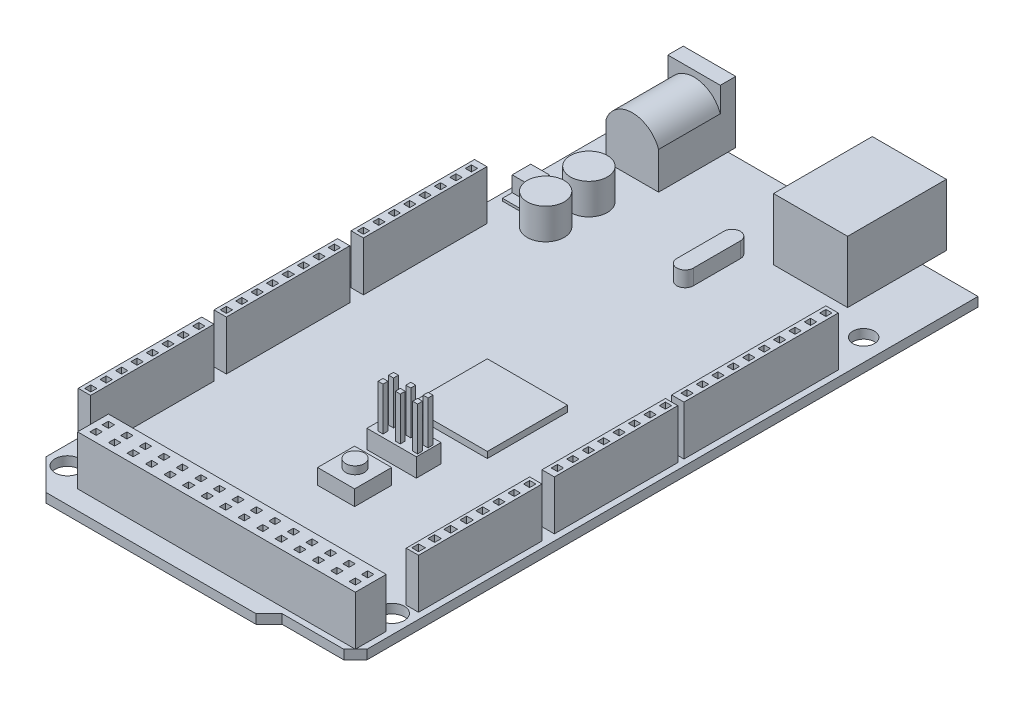
from build123d import *

# Parameters (mm, degrees)
BOSS_EXTRUDE3_DEPTH  = 1.5
SKETCH4_W            = 45
SKETCH4_H            = 5
BOSS_EXTRUDE5_DEPTH  = 8
SKETCH7_W            = 1
SKETCH7_H            = 1
CUT_EXTRUDE1_DEPTH   = 8
SKETCH8_W            = 6
SKETCH8_H            = 6
BOSS_EXTRUDE7_DEPTH  = 2.5
SKETCH10_R           = 1.5
BOSS_EXTRUDE8_DEPTH  = 1.25
SKETCH11_W           = 8
SKETCH11_H           = 4
BOSS_EXTRUDE9_DEPTH  = 3
SKETCH12_W           = 0.8
SKETCH12_H           = 0.8
BOSS_EXTRUDE10_DEPTH = 7
SKETCH13_W           = 13
SKETCH13_H           = 13
BOSS_EXTRUDE11_DEPTH = 1
SKETCH14_W           = 12
SKETCH14_H           = 16
BOSS_EXTRUDE12_DEPTH = 10
CUT_EXTRUDE2_DEPTH   = 13
SKETCH16_W           = 5.556040393
SKETCH16_H           = 3.382310536
BOSS_EXTRUDE13_DEPTH = 13
SKETCH17_W           = 8.5
SKETCH17_H           = 10
BOSS_EXTRUDE14_DEPTH = 1.25
BOSS_EXTRUDE15_DEPTH = 10
SKETCH19_R           = 3
CUT_EXTRUDE6_DEPTH   = 10
SKETCH20_R           = 0.5
BOSS_EXTRUDE16_DEPTH = 8
DOME1_FACE_RADIUS    = 0.5
DOME1_HEIGHT         = 1
SKETCH21_R           = 3
BOSS_EXTRUDE17_DEPTH = 5
SKETCH23_W           = 3.025680813
SKETCH23_H           = 6.185836328
BOSS_EXTRUDE18_DEPTH = 0.4
SKETCH24_W           = 3.025680813
SKETCH24_H           = 3.010787739
BOSS_EXTRUDE19_DEPTH = 2.5
BOSS_EXTRUDE20_DEPTH = 2.5
SKETCH26_R           = 2
CUT_EXTRUDE7_DEPTH   = 1.5
SKETCH27_R           = 2
CUT_EXTRUDE8_DEPTH   = 1.5
SKETCH28_R           = 2
CUT_EXTRUDE9_DEPTH   = 1.5
SKETCH29_W           = 2
SKETCH29_H           = 20
BOSS_EXTRUDE21_DEPTH = 8
SKETCH30_W           = 1
SKETCH30_H           = 1
SKETCH30_W_2         = 1.1
SKETCH30_H_2         = 1.1
CUT_EXTRUDE10_DEPTH  = 8
SKETCH32_W           = 2
SKETCH32_H           = 20
BOSS_EXTRUDE22_DEPTH = 8
SKETCH34_W           = 1
SKETCH34_H           = 1
CUT_EXTRUDE11_DEPTH  = 8
LPATTERN1_COUNT      = 8
LPATTERN1_PITCH      = 2.5
SKETCH37_W           = 2
SKETCH37_H           = 25
BOSS_EXTRUDE24_DEPTH = 8
SKETCH41_W           = 1
SKETCH41_H           = 1
CUT_EXTRUDE13_DEPTH  = 8
LPATTERN3_COUNT      = 10
LPATTERN3_PITCH      = 2.5
SKETCH45_R           = 1.75
CUT_EXTRUDE14_DEPTH  = 1.5
SKETCH46_W           = 2
SKETCH46_H           = 20
BOSS_EXTRUDE25_DEPTH = 8
SKETCH47_W           = 1
SKETCH47_H           = 1
CUT_EXTRUDE15_DEPTH  = 8
LPATTERN4_COUNT      = 8
LPATTERN4_PITCH      = 2.5
SKETCH49_W           = 2
SKETCH49_H           = 20
BOSS_EXTRUDE26_DEPTH = 8
SKETCH50_W           = 1
SKETCH50_H           = 1
CUT_EXTRUDE16_DEPTH  = 8
LPATTERN5_COUNT      = 8
LPATTERN5_PITCH      = 2.5
SKETCH52_W           = 2
SKETCH52_H           = 20
BOSS_EXTRUDE27_DEPTH = 8
SKETCH53_W           = 1
SKETCH53_H           = 1
CUT_EXTRUDE17_DEPTH  = 8
LPATTERN6_COUNT      = 8
LPATTERN6_PITCH      = 2.5


with BuildPart() as part:
    # Sketch1 → Boss-Extrude3 (new body)
    with BuildSketch(Plane(origin=(0, 0, 0), x_dir=(1, 0, 0), z_dir=(0, 1, 0))):
        Polygon((0, 0), (34, 0), (36.121320344, 2.121320344), (46.121320344, 2.121320344), (48, 4), (48, 103), (-5, 103), (-5, 5), align=None)
    extrude(amount=BOSS_EXTRUDE3_DEPTH)

    # Sketch4 → Boss-Extrude5 (add)
    with BuildSketch(Plane(origin=(0, 1.5, 0), x_dir=(1, 0, 0), z_dir=(0, 1, 0))):
        with Locations((24.560660172, 5.560660172)):
            Rectangle(SKETCH4_W, SKETCH4_H)
    extrude(amount=BOSS_EXTRUDE5_DEPTH)

    # Sketch7 → Cut-Extrude1 (cut)
    with BuildSketch(Plane(origin=(0, 9.5, 0), x_dir=(1, 0, 0), z_dir=(0, 1, 0))):
        with Locations((45.560660172, 6.560660172)):
            Rectangle(SKETCH7_W, SKETCH7_H)
        with Locations((45.560660172, 4.560660172)):
            Rectangle(SKETCH7_W, SKETCH7_H)
        with Locations((42.560660172, 4.560660172)):
            Rectangle(SKETCH7_W, SKETCH7_H)
        with Locations((42.560660172, 6.540676592)):
            Rectangle(SKETCH7_W, SKETCH7_H)
        with Locations((39.560660172, 6.540676592)):
            Rectangle(SKETCH7_W, SKETCH7_H)
        with Locations((39.560660172, 4.560660172)):
            Rectangle(SKETCH7_W, SKETCH7_H)
        with Locations((36.560660172, 4.560660172)):
            Rectangle(SKETCH7_W, SKETCH7_H)
        with Locations((36.560660172, 6.540676592)):
            Rectangle(SKETCH7_W, SKETCH7_H)
        with Locations((33.560660172, 6.540676592)):
            Rectangle(SKETCH7_W, SKETCH7_H)
        with Locations((33.560660172, 4.560660172)):
            Rectangle(SKETCH7_W, SKETCH7_H)
        with Locations((30.560660172, 4.560660172)):
            Rectangle(SKETCH7_W, SKETCH7_H)
        with Locations((30.560660172, 6.540676592)):
            Rectangle(SKETCH7_W, SKETCH7_H)
        with Locations((27.560660172, 6.540676592)):
            Rectangle(SKETCH7_W, SKETCH7_H)
        with Locations((27.560660172, 4.560660172)):
            Rectangle(SKETCH7_W, SKETCH7_H)
        with Locations((24.560660172, 6.540676592)):
            Rectangle(SKETCH7_W, SKETCH7_H)
        with Locations((21.560660172, 6.540676592)):
            Rectangle(SKETCH7_W, SKETCH7_H)
        with Locations((24.560660172, 4.560660172)):
            Rectangle(SKETCH7_W, SKETCH7_H)
        with Locations((18.560660172, 6.540676592)):
            Rectangle(SKETCH7_W, SKETCH7_H)
        with Locations((15.560660172, 6.540676592)):
            Rectangle(SKETCH7_W, SKETCH7_H)
        with Locations((21.560660172, 4.560660172)):
            Rectangle(SKETCH7_W, SKETCH7_H)
        with Locations((18.560660172, 4.560660172)):
            Rectangle(SKETCH7_W, SKETCH7_H)
        with Locations((12.560660172, 6.540676592)):
            Rectangle(SKETCH7_W, SKETCH7_H)
        with Locations((9.560660172, 6.540676592)):
            Rectangle(SKETCH7_W, SKETCH7_H)
        with Locations((15.560660172, 4.560660172)):
            Rectangle(SKETCH7_W, SKETCH7_H)
        with Locations((6.560660172, 6.540676592)):
            Rectangle(SKETCH7_W, SKETCH7_H)
        with Locations((3.560660172, 6.540676592)):
            Rectangle(SKETCH7_W, SKETCH7_H)
        with Locations((12.560660172, 4.560660172)):
            Rectangle(SKETCH7_W, SKETCH7_H)
        with Locations((9.560660172, 4.560660172)):
            Rectangle(SKETCH7_W, SKETCH7_H)
        with Locations((6.560660172, 4.560660172)):
            Rectangle(SKETCH7_W, SKETCH7_H)
        with Locations((3.560660172, 4.560660172)):
            Rectangle(SKETCH7_W, SKETCH7_H)
    extrude(amount=-CUT_EXTRUDE1_DEPTH, mode=Mode.SUBTRACT)

    # Sketch8 → Boss-Extrude7 (add)
    with BuildSketch(Plane(origin=(0, 1.5, 0), x_dir=(1, 0, 0), z_dir=(0, 1, 0))):
        with Locations((24, 26)):
            Rectangle(SKETCH8_W, SKETCH8_H)
    extrude(amount=BOSS_EXTRUDE7_DEPTH)

    # Sketch10 → Boss-Extrude8 (add)
    with BuildSketch(Plane(origin=(0, 4, 0), x_dir=(1, 0, 0), z_dir=(0, 1, 0))):
        with Locations((24, 26.073311565)):
            Circle(SKETCH10_R)
    extrude(amount=BOSS_EXTRUDE8_DEPTH)

    # Sketch11 → Boss-Extrude9 (add)
    with BuildSketch(Plane(origin=(0, 1.5, 0), x_dir=(1, 0, 0), z_dir=(0, 1, 0))):
        with Locations((24, 34)):
            Rectangle(SKETCH11_W, SKETCH11_H)
    extrude(amount=BOSS_EXTRUDE9_DEPTH)

    # Sketch12 → Boss-Extrude10 (add)
    with BuildSketch(Plane(origin=(0, 4.5, 0), x_dir=(1, 0, 0), z_dir=(0, 1, 0))):
        with Locations((27.3, 34.6)):
            Rectangle(SKETCH12_W, SKETCH12_H)
        with Locations((24.5, 34.6)):
            Rectangle(SKETCH12_W, SKETCH12_H)
        with Locations((21.7, 34.6)):
            Rectangle(SKETCH12_W, SKETCH12_H)
        with Locations((21.7, 32.9)):
            Rectangle(SKETCH12_W, SKETCH12_H)
        with Locations((24.5, 32.9)):
            Rectangle(SKETCH12_W, SKETCH12_H)
        with Locations((27.3, 32.9)):
            Rectangle(SKETCH12_W, SKETCH12_H)
    extrude(amount=BOSS_EXTRUDE10_DEPTH)

    # Sketch13 → Boss-Extrude11 (add)
    with BuildSketch(Plane(origin=(0, 1.5, 0), x_dir=(1, 0, 0), z_dir=(0, 1, 0))):
        with Locations((24.5, 47)):
            Rectangle(SKETCH13_W, SKETCH13_H)
    extrude(amount=BOSS_EXTRUDE11_DEPTH)

    # Sketch14 → Boss-Extrude12 (add)
    with BuildSketch(Plane(origin=(0, 1.5, 0), x_dir=(1, 0, 0), z_dir=(0, 1, 0))):
        with Locations((33, 98.872790312)):
            Rectangle(SKETCH14_W, SKETCH14_H)
    extrude(amount=BOSS_EXTRUDE12_DEPTH)

    # Sketch15 → Cut-Extrude2 (cut)
    with BuildSketch(Plane(origin=(0, 0, -106.872790312), x_dir=(-1, 0, 0), z_dir=(0, 0, -1))):
        Polygon((-37.504201852, 2.874498731), (-37.504201852, 7.776667234), (-35.780869086, 9.5), (-30.271494225, 9.5), (-28.548161459, 7.776667234), (-28.548161459, 2.874498731), align=None)
    extrude(amount=-CUT_EXTRUDE2_DEPTH, mode=Mode.SUBTRACT)

    # Sketch16 → Boss-Extrude13 (add)
    with BuildSketch(Plane(origin=(0, 0, -93.872790312), x_dir=(-1, 0, 0), z_dir=(0, 0, -1))):
        with Locations((-33.026181656, 6.088795598)):
            Rectangle(SKETCH16_W, SKETCH16_H)
    extrude(amount=BOSS_EXTRUDE13_DEPTH)

    # Sketch17 → Boss-Extrude14 (add, symmetric)
    with BuildSketch(Plane(origin=(0, 0, -103), x_dir=(-1, 0, 0), z_dir=(0, 0, -1))):
        with Locations((-3.25, 6.5)):
            Rectangle(SKETCH17_W, SKETCH17_H)
    extrude(amount=BOSS_EXTRUDE14_DEPTH, both=True)

    # Sketch18 → Boss-Extrude15 (add)
    with BuildSketch(Plane.XY.offset(-101.75)):
        with BuildLine():
            Line((-1, 7.5), (-1, 1.5))
            Line((-1, 1.5), (7.5, 1.5))
            Line((7.5, 1.5), (7.5, 7.5))
            ThreePointArc((7.5, 7.5), (3.25, 10.520980054), (-1, 7.5))
        make_face()
    extrude(amount=BOSS_EXTRUDE15_DEPTH)

    # Sketch19 → Cut-Extrude6 (cut)
    with BuildSketch(Plane(origin=(0, 0, -104.25), x_dir=(-1, 0, 0), z_dir=(0, 0, -1))):
        with Locations((-3, 6.5)):
            Circle(SKETCH19_R)
    extrude(amount=-CUT_EXTRUDE6_DEPTH, mode=Mode.SUBTRACT)

    # Sketch20 → Boss-Extrude16 (add)
    with BuildSketch(Plane(origin=(0, 0, -94.25), x_dir=(-1, 0, 0), z_dir=(0, 0, -1))):
        with Locations((-3, 6.5)):
            Circle(SKETCH20_R)
    extrude(amount=BOSS_EXTRUDE16_DEPTH)

    # Dome1: a dome of height H over a round flat face of radius A is a cap of a sphere of radius (A * A + H * H) / (2 * H)
    dome1_r = (DOME1_FACE_RADIUS * DOME1_FACE_RADIUS + DOME1_HEIGHT * DOME1_HEIGHT) / (2 * DOME1_HEIGHT)
    dome1_base = Plane((3, 6.5, -102.25), z_dir=(0, 0, -1))
    with Locations(dome1_base.offset(DOME1_HEIGHT - dome1_r)):
        dome1_ball = Sphere(dome1_r, mode=Mode.PRIVATE)
    add(split(dome1_ball, bisect_by=dome1_base, keep=Keep.TOP, mode=Mode.PRIVATE))

    # Sketch21 → Boss-Extrude17 (add)
    with BuildSketch(Plane(origin=(0, 1.5, 0), x_dir=(1, 0, 0), z_dir=(0, 1, 0))):
        with Locations((3.204807184, 84.75)):
            Circle(SKETCH21_R)
        with Locations((3.204807184, 77.75)):
            Circle(SKETCH21_R)
    extrude(amount=BOSS_EXTRUDE17_DEPTH)

    # Sketch23 → Boss-Extrude18 (add)
    with BuildSketch(Plane(origin=(0, 1.5, 0), x_dir=(1, 0, 0), z_dir=(0, 1, 0))):
        with Locations((-2.384923748, 80.942657666)):
            Rectangle(SKETCH23_W, SKETCH23_H)
    extrude(amount=BOSS_EXTRUDE18_DEPTH)

    # Sketch24 → Boss-Extrude19 (add)
    with BuildSketch(Plane(origin=(0, 1.9, 0), x_dir=(1, 0, 0), z_dir=(0, 1, 0))):
        with Locations((-2.384923748, 80.930065048)):
            Rectangle(SKETCH24_W, SKETCH24_H)
    extrude(amount=BOSS_EXTRUDE19_DEPTH)

    # Sketch25 → Boss-Extrude20 (add)
    with BuildSketch(Plane(origin=(0, 1.5, 0), x_dir=(1, 0, 0), z_dir=(0, 1, 0))):
        with BuildLine():
            Line((20.771758804, 89.050138078), (20.771758804, 81.430202035))
            ThreePointArc((20.771758804, 81.430202035), (22.112303108, 80.089657731), (23.452847412, 81.430202035))
            Line((23.452847412, 81.430202035), (23.452847412, 89.050138078))
            ThreePointArc((23.452847412, 89.050138078), (22.112303108, 90.390682382), (20.771758804, 89.050138078))
        make_face()
    extrude(amount=BOSS_EXTRUDE20_DEPTH)

    # Sketch26 → Cut-Extrude7 (cut)
    with BuildSketch(Plane(origin=(0, 1.5, 0), x_dir=(1, 0, 0), z_dir=(0, 1, 0))):
        with Locations((-2, 89)):
            Circle(SKETCH26_R)
    extrude(amount=-CUT_EXTRUDE7_DEPTH, mode=Mode.SUBTRACT)

    # Sketch27 → Cut-Extrude8 (cut)
    with BuildSketch(Plane(origin=(0, 1.5, 0), x_dir=(1, 0, 0), z_dir=(0, 1, 0))):
        with Locations((-2, 5.472916024)):
            Circle(SKETCH27_R)
    extrude(amount=-CUT_EXTRUDE8_DEPTH, mode=Mode.SUBTRACT)

    # Sketch28 → Cut-Extrude9 (cut)
    with BuildSketch(Plane(origin=(0, 1.5, 0), x_dir=(1, 0, 0), z_dir=(0, 1, 0))):
        with Locations((45, 11.060660172)):
            Circle(SKETCH28_R)
    extrude(amount=-CUT_EXTRUDE9_DEPTH, mode=Mode.SUBTRACT)

    # Sketch29 → Boss-Extrude21 (add)
    with BuildSketch(Plane(origin=(0, 1.5, 0), x_dir=(1, 0, 0), z_dir=(0, 1, 0))):
        with Locations((46, 23.360660172)):
            Rectangle(SKETCH29_W, SKETCH29_H)
    extrude(amount=BOSS_EXTRUDE21_DEPTH)

    # Sketch30 → Cut-Extrude10 (cut)
    with BuildSketch(Plane(origin=(0, 9.5, 0), x_dir=(1, 0, 0), z_dir=(0, 1, 0))):
        with Locations((46, 32.360660172)):
            Rectangle(SKETCH30_W, SKETCH30_H)
        with Locations((46, 29.860660172)):
            Rectangle(SKETCH30_W, SKETCH30_H)
        with Locations((46, 27.360660172)):
            Rectangle(SKETCH30_W, SKETCH30_H)
        with Locations((45.95, 24.810660172)):
            Rectangle(SKETCH30_W_2, SKETCH30_H_2)
        with Locations((45.95, 22.210660172)):
            Rectangle(SKETCH30_W_2, SKETCH30_H_2)
        with Locations((45.95, 19.610660172)):
            Rectangle(SKETCH30_W_2, SKETCH30_H_2)
        with Locations((45.95, 17.010660172)):
            Rectangle(SKETCH30_W_2, SKETCH30_H_2)
        with Locations((45.95, 14.410660172)):
            Rectangle(SKETCH30_W_2, SKETCH30_H_2)
    extrude(amount=-CUT_EXTRUDE10_DEPTH, mode=Mode.SUBTRACT)

    # Sketch32 → Boss-Extrude22 (add)
    with BuildSketch(Plane(origin=(0, 1.5, 0), x_dir=(1, 0, 0), z_dir=(0, 1, 0))):
        with Locations((46, 45.360660172)):
            Rectangle(SKETCH32_W, SKETCH32_H)
    extrude(amount=BOSS_EXTRUDE22_DEPTH)

    # Sketch34 → Cut-Extrude11 (cut)
    with BuildSketch(Plane(origin=(0, 9.5, 0), x_dir=(1, 0, 0), z_dir=(0, 1, 0))):
        with Locations((46, 54.360660172)):
            Rectangle(SKETCH34_W, SKETCH34_H)
    cut_extrude11 = extrude(amount=-CUT_EXTRUDE11_DEPTH, mode=Mode.SUBTRACT)

    # LPattern1: Cut-Extrude11 ×8
    with Locations(*[(0, 0, i * LPATTERN1_PITCH) for i in range(1, LPATTERN1_COUNT)]):
        add(cut_extrude11, mode=Mode.SUBTRACT)

    # Sketch37 → Boss-Extrude24 (add)
    with BuildSketch(Plane(origin=(0, 1.5, 0), x_dir=(1, 0, 0), z_dir=(0, 1, 0))):
        with Locations((46, 68.860660172)):
            Rectangle(SKETCH37_W, SKETCH37_H)
    extrude(amount=BOSS_EXTRUDE24_DEPTH)

    # Sketch41 → Cut-Extrude13 (cut)
    with BuildSketch(Plane(origin=(0, 9.5, 0), x_dir=(1, 0, 0), z_dir=(0, 1, 0))):
        with Locations((46, 80.360660172)):
            Rectangle(SKETCH41_W, SKETCH41_H)
    cut_extrude13 = extrude(amount=-CUT_EXTRUDE13_DEPTH, mode=Mode.SUBTRACT)

    # LPattern3: Cut-Extrude13 ×10
    with Locations(*[(0, 0, i * LPATTERN3_PITCH) for i in range(1, LPATTERN3_COUNT)]):
        add(cut_extrude13, mode=Mode.SUBTRACT)

    # Sketch45 → Cut-Extrude14 (cut)
    with BuildSketch(Plane(origin=(0, 1.5, 0), x_dir=(1, 0, 0), z_dir=(0, 1, 0))):
        with Locations((44.475, 88)):
            Circle(SKETCH45_R)
    extrude(amount=-CUT_EXTRUDE14_DEPTH, mode=Mode.SUBTRACT)

    # Sketch46 → Boss-Extrude25 (add)
    with BuildSketch(Plane(origin=(0, 1.5, 0), x_dir=(1, 0, 0), z_dir=(0, 1, 0))):
        with Locations((-3, 19.222916024)):
            Rectangle(SKETCH46_W, SKETCH46_H)
    extrude(amount=BOSS_EXTRUDE25_DEPTH)

    # Sketch47 → Cut-Extrude15 (cut)
    with BuildSketch(Plane(origin=(0, 9.5, 0), x_dir=(1, 0, 0), z_dir=(0, 1, 0))):
        with Locations((-2.966482859, 10.222916024)):
            Rectangle(SKETCH47_W, SKETCH47_H)
    cut_extrude15 = extrude(amount=-CUT_EXTRUDE15_DEPTH, mode=Mode.SUBTRACT)

    # LPattern4: Cut-Extrude15 ×8
    with Locations(*[(0, 0, -i * LPATTERN4_PITCH) for i in range(1, LPATTERN4_COUNT)]):
        add(cut_extrude15, mode=Mode.SUBTRACT)

    # Sketch49 → Boss-Extrude26 (add)
    with BuildSketch(Plane(origin=(0, 1.5, 0), x_dir=(1, 0, 0), z_dir=(0, 1, 0))):
        with Locations((-3, 41.222916024)):
            Rectangle(SKETCH49_W, SKETCH49_H)
    extrude(amount=BOSS_EXTRUDE26_DEPTH)

    # Sketch50 → Cut-Extrude16 (cut)
    with BuildSketch(Plane(origin=(0, 9.5, 0), x_dir=(1, 0, 0), z_dir=(0, 1, 0))):
        with Locations((-3, 32.222916024)):
            Rectangle(SKETCH50_W, SKETCH50_H)
    cut_extrude16 = extrude(amount=-CUT_EXTRUDE16_DEPTH, mode=Mode.SUBTRACT)

    # LPattern5: Cut-Extrude16 ×8
    with Locations(*[(0, 0, -i * LPATTERN5_PITCH) for i in range(1, LPATTERN5_COUNT)]):
        add(cut_extrude16, mode=Mode.SUBTRACT)

    # Sketch52 → Boss-Extrude27 (add)
    with BuildSketch(Plane(origin=(0, 1.5, 0), x_dir=(1, 0, 0), z_dir=(0, 1, 0))):
        with Locations((-3, 63.427355042)):
            Rectangle(SKETCH52_W, SKETCH52_H)
    extrude(amount=BOSS_EXTRUDE27_DEPTH)

    # Sketch53 → Cut-Extrude17 (cut)
    with BuildSketch(Plane(origin=(0, 9.5, 0), x_dir=(1, 0, 0), z_dir=(0, 1, 0))):
        with Locations((-3, 54.427355042)):
            Rectangle(SKETCH53_W, SKETCH53_H)
    cut_extrude17 = extrude(amount=-CUT_EXTRUDE17_DEPTH, mode=Mode.SUBTRACT)

    # LPattern6: Cut-Extrude17 ×8
    with Locations(*[(0, 0, -i * LPATTERN6_PITCH) for i in range(1, LPATTERN6_COUNT)]):
        add(cut_extrude17, mode=Mode.SUBTRACT)


solid = part.part
